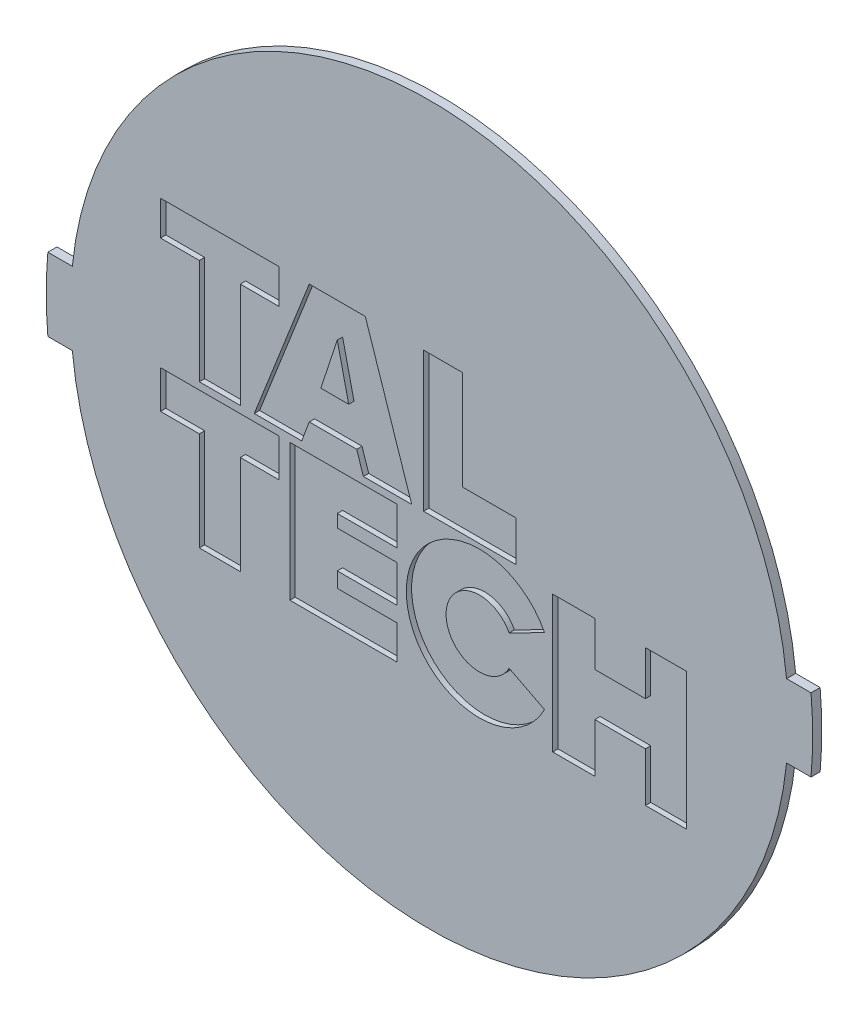
from build123d import *

# Parameters (mm, degrees)
CROQUIS1_R              = 59
SALIENTE_EXTRUIR1_DEPTH = 1.5
SALIENTE_EXTRUIR2_DEPTH = 1.5
ESCALA1_SCALE           = 0.8
CORTAR_EXTRUIR1_DEPTH   = 0.7


with BuildPart() as part:
    # Croquis1 → Saliente-Extruir1 (new body)
    with BuildSketch(Plane.XY):
        Circle(CROQUIS1_R)
    extrude(amount=SALIENTE_EXTRUIR1_DEPTH)

    # Croquis2 → Saliente-Extruir2 (add)
    with BuildSketch(Plane.XY.offset(1.5)):
        with BuildLine():
            Line((-62.713634881, 6), (62.713634881, 6))
            ThreePointArc((62.713634881, 6), (63, 0), (62.713634881, -6))
            Line((62.713634881, -6), (-62.713634881, -6))
            ThreePointArc((-62.713634881, -6), (-63, 0), (-62.713634881, 6))
        make_face()
    extrude(amount=-SALIENTE_EXTRUIR2_DEPTH)


with BuildPart() as part_1:
    # Escala1: scaled about (0, 0, 0.75)
    add(part.part.scale(ESCALA1_SCALE).moved(Location((0, 0, 0.15))))

    # Croquis7 → Cortar-Extruir1 (cut)
    with BuildSketch(Plane.XY.offset(1.35)):
        Polygon((-0.779467376, 0), (-0.779467376, 5.314550288), (-0.779467376, 18.352913661), (4.322500901, 18.352913661), (4.322500901, 5.314550288), (11.408567952, 5.314550288), (11.408567952, 0), align=None)
        Polygon((-15.801929523, 18.352913661), (-23.029717915, 0), (-16.79397891, 0), (-15.801929523, 2.657275144), (-9.566190518, 2.657275144), (-8.684228244, 0), (-2.338402127, 0), (-8.429821566, 18.352913661), align=None)
        Polygon((-10.617093295, 7.257317405), (-14.282649957, 7.257317405), (-12.115875544, 13.817830749), align=None, mode=Mode.SUBTRACT)
        Polygon((-24.872095348, 0), (-24.872095348, 13.817830749), (-19.770127071, 13.817830749), (-19.770127071, 18.352913661), (-35.359474583, 18.352913661), (-35.359474583, 13.817830749), (-30.257506306, 13.817830749), (-30.257506306, 0), align=None)
        Polygon((-24.872095348, -18.919799025), (-24.872095348, -5.925877823), (-19.770127071, -5.925877823), (-19.770127071, -0.941442838), (-35.359474583, -0.941442838), (-35.359474583, -5.925877823), (-30.257506306, -5.925877823), (-30.257506306, -18.919799025), align=None)
        Polygon((-4.281500949, -14.454799909), (-4.281500949, -18.919799025), (-18.34868413, -18.919799025), (-18.34868413, -0.941442838), (-4.281500949, -0.941442838), (-4.281500949, -5.925877823), (-12.115875544, -5.925877823), (-12.115875544, -7.587356151), (-4.281500949, -7.587356151), (-4.281500949, -12.461025915), (-12.115875544, -12.461025915), (-12.115875544, -14.454799909), align=None)
        with BuildLine():
            ThreePointArc((10.477188742, -8.24524686), (2.187062141, -10.245721477), (10.477188742, -12.246196094))
            Line((10.477188742, -12.246196094), (15.133105793, -14.632150132))
            ThreePointArc((15.133105793, -14.632150132), (-3.044604921, -10.245721477), (15.133105793, -5.859292822))
            Line((15.133105793, -5.859292822), (10.477188742, -8.24524686))
        make_face()
        Polygon((28.394239509, -12.461025915), (28.394239509, -18.919799025), (33.800539832, -18.919799025), (33.800539832, -0.941442838), (28.394239509, -0.941442838), (28.394239509, -6.756616987), (21.748326196, -6.756616987), (21.748326196, -0.941442838), (16.210065101, -0.941442838), (16.210065101, -18.919799025), (21.748326196, -18.919799025), (21.748326196, -12.461025915), align=None)
    extrude(amount=-CORTAR_EXTRUIR1_DEPTH, mode=Mode.SUBTRACT)


solid = part_1.part
